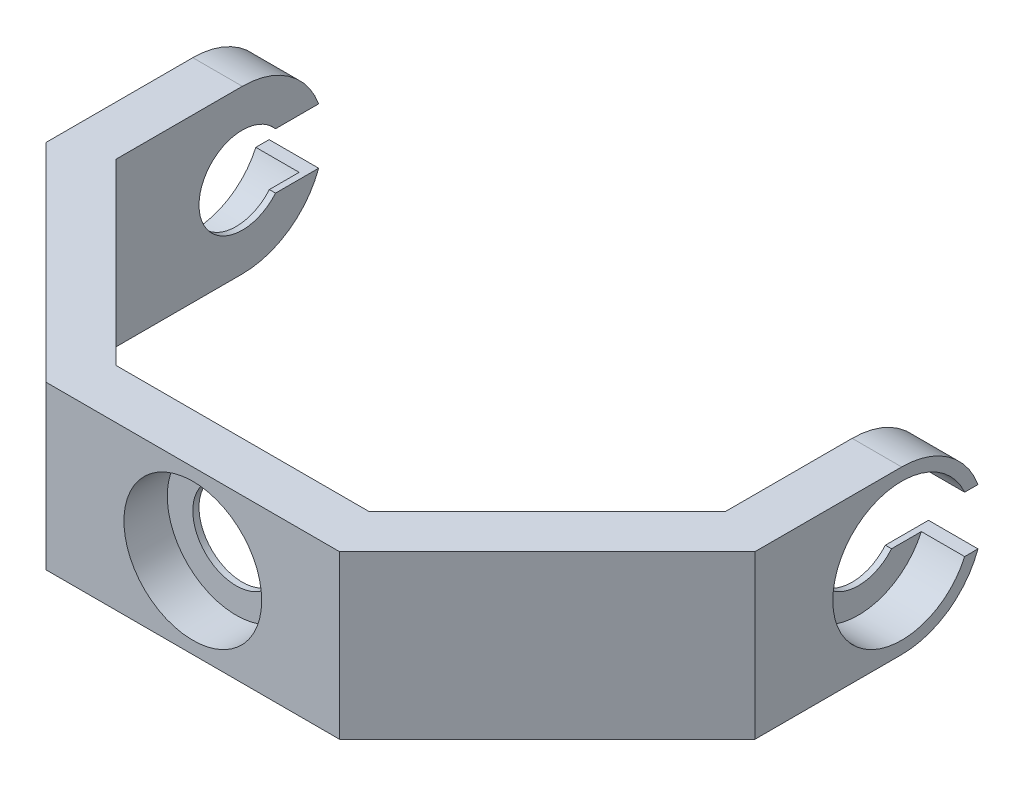
from build123d import *

# Parameters (mm, degrees)
BOSS_EXTRUDE1_DEPTH = 13.125
CUT_EXTRUDE1_REACH  = 130.686
CUT_EXTRUDE2_DEPTH  = 7
SKETCH3_R           = 11.125
CUT_EXTRUDE3_DEPTH  = 7
CUT_EXTRUDE4_REACH  = 87.826
SKETCH4_R           = 7


with BuildPart() as part:
    # Sketch1 → Boss-Extrude1 (new, symmetric)
    with BuildSketch(Plane(origin=(0, 0, 0), x_dir=(1, 0, 0), z_dir=(0, 1, 0))):
        Polygon((-49.25, 13.125), (-49.25, -13.125), (-49.25, -20.400017947), (-20.400017947, -49.25), (20.400017947, -49.25), (49.25, -20.400017947), (49.25, -13.125), (49.25, 13.125), (57.25, 13.125), (57.25, -23.713726446), (23.713726446, -57.25), (-23.713726446, -57.25), (-57.25, -23.713726446), (-57.25, 13.125), align=None)
    extrude(amount=BOSS_EXTRUDE1_DEPTH, both=True)

    # Sketch2 → Cut-Extrude1 (cut, up to next)
    with BuildSketch(Plane.ZY.offset(57.25), mode=Mode.PRIVATE) as cut_extrude1_sk1:
        with BuildLine():
            ThreePointArc((-5.361902647, -4.5), (7, 0), (-5.361902647, 4.5))
            Line((-5.361902647, 4.5), (-12.329461667, 4.5))
            ThreePointArc((-12.329461667, 4.5), (-7.523400993, 10.7547228), (0, 13.125))
            Line((0, 13.125), (-13.125, 13.125))
            Line((-13.125, 13.125), (-13.125, -13.125))
            Line((-13.125, -13.125), (0, -13.125))
            ThreePointArc((0, -13.125), (-7.523400993, -10.7547228), (-12.329461667, -4.5))
            Line((-12.329461667, -4.5), (-5.361902647, -4.5))
        make_face()
    cut_extrude1_tool1 = extrude(cut_extrude1_sk1.sketch, amount=-CUT_EXTRUDE1_REACH, mode=Mode.PRIVATE) & part.part
    cut_extrude1 = cut_extrude1_tool1.solids().sort_by_distance((-57.25, 0, -4.585873))[0]
    add(cut_extrude1, mode=Mode.SUBTRACT)

    # Sketch2_4 → Cut-Extrude2 (cut)
    with BuildSketch(Plane.ZY.offset(57.25)):
        with BuildLine():
            Line((-10.174262873, 4.5), (-5.361902647, 4.5))
            ThreePointArc((-5.361902647, 4.5), (2.394439545, 6.577739678), (7, 0))
            ThreePointArc((7, 0), (2.394439545, -6.577739678), (-5.361902647, -4.5))
            Line((-5.361902647, -4.5), (-10.174262873, -4.5))
            ThreePointArc((-10.174262873, -4.5), (2.299668513, -10.88472093), (11.125, 0))
            ThreePointArc((11.125, 0), (2.299668513, 10.88472093), (-10.174262873, 4.5))
        make_face()
    cut_extrude2 = extrude(amount=-CUT_EXTRUDE2_DEPTH, mode=Mode.SUBTRACT)

    # Mirror1: Cut-Extrude1, Cut-Extrude2 across plane
    add(cut_extrude1.mirror(Plane(origin=(0, 0, 0), x_dir=(0, 0, 1), z_dir=(1, 0, 0))), mode=Mode.SUBTRACT)
    add(cut_extrude2.mirror(Plane(origin=(0, 0, 0), x_dir=(0, 0, 1), z_dir=(1, 0, 0))), mode=Mode.SUBTRACT)

    # Sketch3 → Cut-Extrude3 (cut)
    with BuildSketch(Plane.XY.offset(57.25)):
        Circle(SKETCH3_R)
    extrude(amount=-CUT_EXTRUDE3_DEPTH, mode=Mode.SUBTRACT)

    # Sketch4 → Cut-Extrude4 (cut, up to next)
    with BuildSketch(Plane.XY.offset(50.25), mode=Mode.PRIVATE) as cut_extrude4_sk1:
        Circle(SKETCH4_R)
    cut_extrude4_tool1 = extrude(cut_extrude4_sk1.sketch, amount=-CUT_EXTRUDE4_REACH, mode=Mode.PRIVATE) & part.part
    add(cut_extrude4_tool1.solids().sort_by_distance((0, 0, 50.25))[0], mode=Mode.SUBTRACT)


solid = part.part
